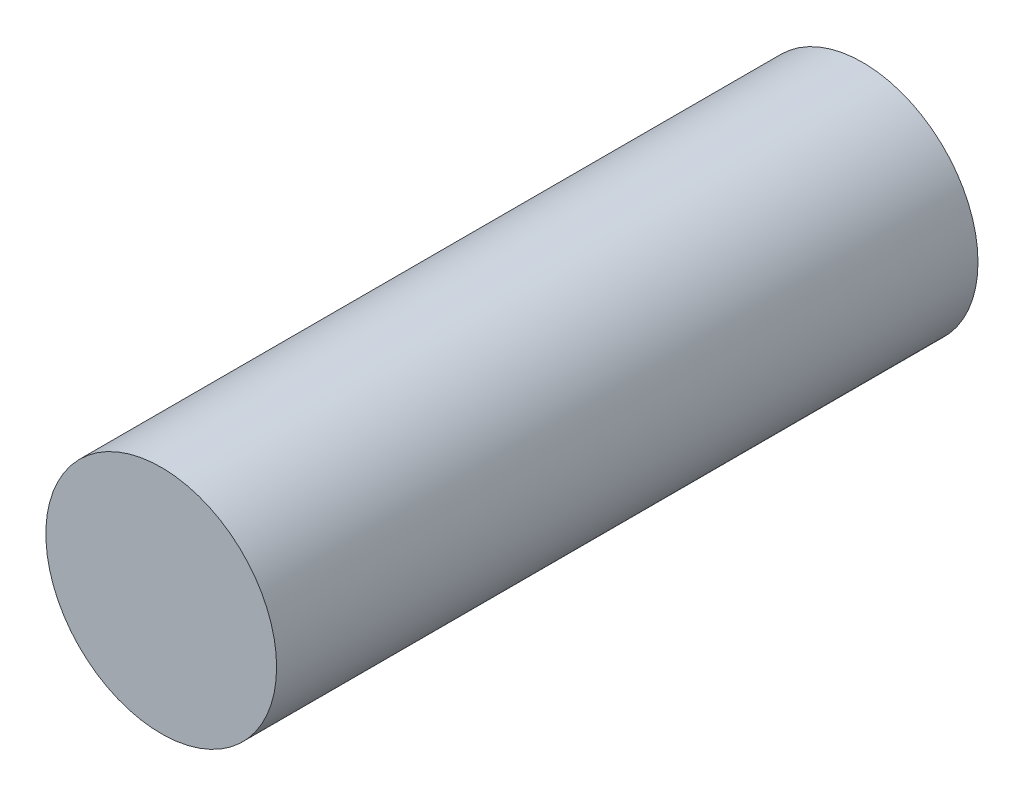
from build123d import *

# Parameters (mm, degrees)
ESQUISSE1_R             = 5.05
BOSS_EXTRU_1_DEPTH      = 30.7
ESQUISSE2_R             = 2.05
ENL_V_MAT_EXTRU_1_DEPTH = 2.65


with BuildPart() as part:
    # Esquisse1 → Boss.-Extru.1 (new body)
    with BuildSketch(Plane.XY):
        Circle(ESQUISSE1_R)
    extrude(amount=BOSS_EXTRU_1_DEPTH)

    # Esquisse2 → Enlèv. mat.-Extru.1 (cut)
    with BuildSketch(Plane(origin=(0, 0, 0), x_dir=(-1, 0, 0), z_dir=(0, 0, -1))):
        Circle(ESQUISSE2_R)
    extrude(amount=-ENL_V_MAT_EXTRU_1_DEPTH, mode=Mode.SUBTRACT)


solid = part.part
